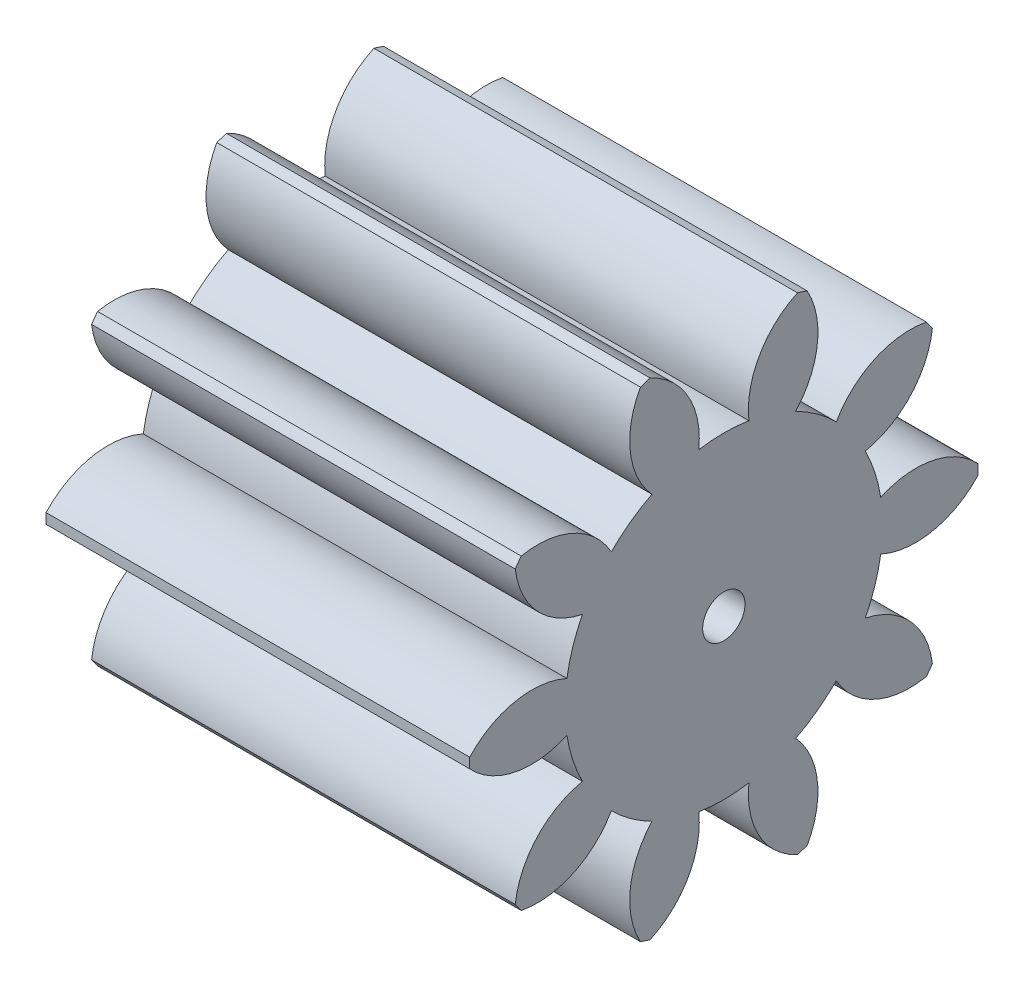
from build123d import *

# Parameters (mm, degrees)
BASPROSKE_W     = 8
BASPROSKE_H     = 4.8
TOOTHCUT_DEPTH  = 11.491901639
TEETHCUTS_COUNT = 10
TEETHCUTS_ANGLE = 324
BORSKE_R        = 0.4
BORE_DEPTH      = 50.0000508


with BuildPart() as part:
    # BasProSke → Base-Revolve (revolve)
    with BuildSketch(Plane(origin=(0, 0, 0), x_dir=(1, 0, 0), z_dir=(0, 1, 0)), mode=Mode.PRIVATE) as base_revolve_sk:
        with Locations((4, 2.4)):
            Rectangle(BASPROSKE_W, BASPROSKE_H)
    revolve(base_revolve_sk.sketch.rotate(Axis((-10, 0, 0), (1, 0, 0)), 180), axis=Axis((-10, 0, 0), (1, 0, 0)))

    # TooCutSke → ToothCut (cut, through all)
    with BuildSketch(Plane(origin=(0, 0, 0), x_dir=(0, 0, -1), z_dir=(1, 0, 0))):
        with BuildLine():
            ThreePointArc((0.473726058, 2.961348446), (0, 2.999), (-0.473726058, 2.961348446))
            ThreePointArc((-0.473726058, 2.961348446), (-0.678470427, 3.942691912), (-1.42693485, 4.6095924))
            ThreePointArc((-1.42693485, 4.6095924), (0, 4.8254), (1.42693485, 4.6095924))
            ThreePointArc((1.42693485, 4.6095924), (0.678470427, 3.942691912), (0.473726058, 2.961348446))
        make_face()
    toothcut = extrude(amount=TOOTHCUT_DEPTH, mode=Mode.SUBTRACT)

    # TeethCuts: ToothCut ×10 about axis
    teethcuts_axis = Axis((-10, 0, 0), (1, 0, 0))
    for i in range(1, TEETHCUTS_COUNT):
        add(toothcut.rotate(teethcuts_axis, i * TEETHCUTS_ANGLE / (TEETHCUTS_COUNT - 1)), mode=Mode.SUBTRACT)

    # BorSke → Bore (cut, symmetric)
    with BuildSketch(Plane(origin=(0, 0, 0), x_dir=(0, 0, -1), z_dir=(1, 0, 0))):
        with Locations(Location((0, 0, 0), (0, 0, 180))):
            Circle(BORSKE_R)
    extrude(amount=BORE_DEPTH, both=True, mode=Mode.SUBTRACT)


solid = part.part
